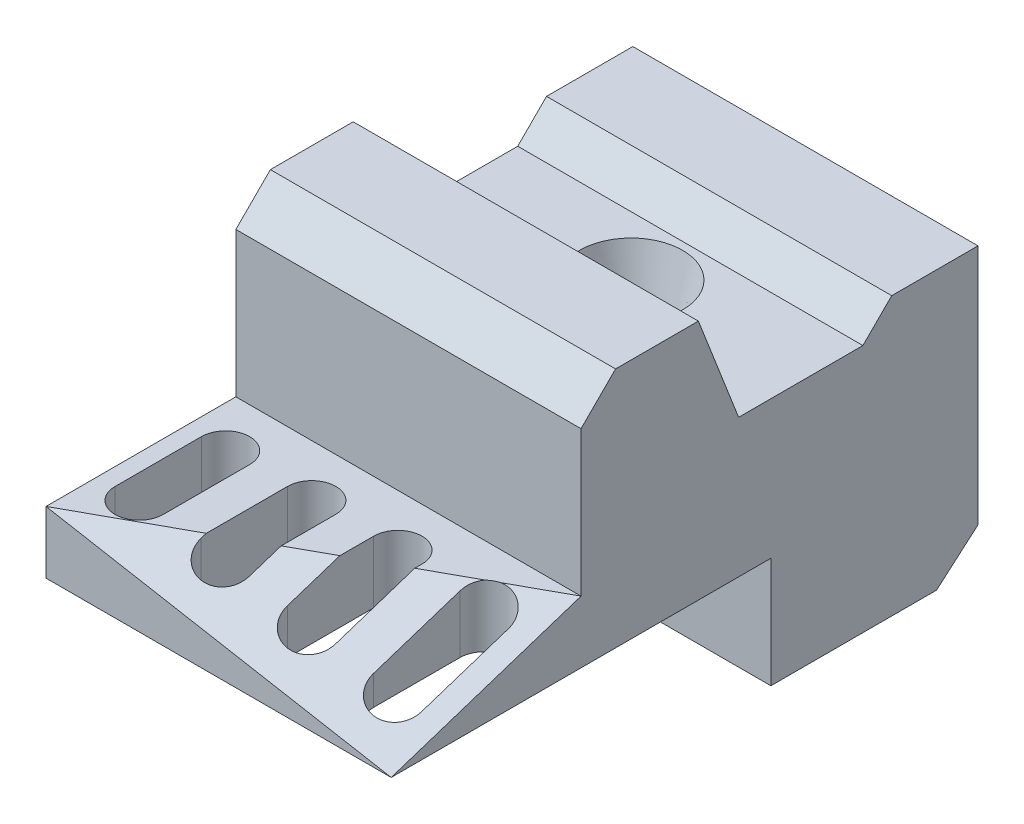
from build123d import *

# Parameters (mm, degrees)
RESSALTO_EXTRUS_O1_DEPTH = 100
CORTE_EXTRUS_O1_DEPTH    = 51.001510114
CORTE_EXTRUS_O4_DEPTH    = 87
CORTE_EXTRUS_O6_DEPTH    = 20
CORTE_EXTRUS_O8_REACH    = 104
ESBO_O10_R               = 9
ESBO_O12_R               = 14.94
CORTE_EXTRUS_O10_DEPTH   = 24.04
CORTE_EXTRUS_O10_TAPER   = 12.85


with BuildPart() as part:
    # Esboço3 → Ressalto-extrusão1 (new body)
    with BuildSketch(Plane(origin=(0, 0, 0), x_dir=(0, 0, -1), z_dir=(1, 0, 0))):
        Polygon((0, 0), (0, -70), (-12, -80.38), (-60, -80.38), (-60, -48.378489886), (-170, -48.378489886), (-170, -30.378489886), (-115, -30.378489886), (-115, 11.621510114), (-105.001510114, 21.62), (-81.001510114, 21.62), (-69.343860018, -8.343860018), (-33.343860018, -8.343860018), (-25, 0), align=None)
    extrude(amount=RESSALTO_EXTRUS_O1_DEPTH)

    # Esboço5 → Corte-extrusão1 (cut, through all)
    with BuildSketch(Plane(origin=(0, -30.378489886, 0), x_dir=(1, 0, 0), z_dir=(0, 1, 0))):
        with BuildLine():
            Line((5, -155.02), (5, -129.98))
            ThreePointArc((5, -129.98), (12, -122.98), (19, -129.98))
            Line((19, -129.98), (19, -155.02))
            ThreePointArc((19, -155.02), (12, -162.02), (5, -155.02))
        make_face()
        with BuildLine():
            Line((29.96, -155.02), (29.96, -129.98))
            ThreePointArc((29.96, -129.98), (36.96, -122.98), (43.96, -129.98))
            Line((43.96, -129.98), (43.96, -155.02))
            ThreePointArc((43.96, -155.02), (36.96, -162.02), (29.96, -155.02))
        make_face()
        with BuildLine():
            Line((54.92, -155.02), (54.92, -129.98))
            ThreePointArc((54.92, -129.98), (61.92, -122.98), (68.92, -129.98))
            Line((68.92, -129.98), (68.92, -155.02))
            ThreePointArc((68.92, -155.02), (61.92, -162.02), (54.92, -155.02))
        make_face()
        with BuildLine():
            Line((79.88, -155.02), (79.88, -129.98))
            ThreePointArc((79.88, -129.98), (86.88, -122.98), (93.88, -129.98))
            Line((93.88, -129.98), (93.88, -155.02))
            ThreePointArc((93.88, -155.02), (86.88, -162.02), (79.88, -155.02))
        make_face()
    extrude(amount=-CORTE_EXTRUS_O1_DEPTH, mode=Mode.SUBTRACT)

    # Esboço6 → Corte-extrusão4 (cut)
    with BuildSketch(Plane(origin=(3.989809214, 22.165606742, 7.25419857), x_dir=(0.985680811, -0.160257749, -0.052447991), z_dir=(0.168621878, 0.936788213, 0.306585233))):
        Polygon((-4.047769995, -171.016408889), (97.404950637, -176.615111976), (97.404950637, -118.744566791), align=None)
    extrude(amount=CORTE_EXTRUS_O4_DEPTH, mode=Mode.SUBTRACT)

    # Esboço9 → Corte-extrusão6 (cut)
    with BuildSketch(Plane.ZY):
        Polygon((105, 11.62), (87.841109365, 11.62), (76.183459269, -18.343860018), (29.781857804, -18.343860018), (21.437997786, -10), (10, -10), (10, -65.427954016), (15.724908652, -70.38), (50, -70.38), (50, -38.378489886), (105, -38.378489886), align=None)
    extrude(amount=-CORTE_EXTRUS_O6_DEPTH, mode=Mode.SUBTRACT)

    # Esboço10 → Corte-extrusão8 (cut, up to next)
    with BuildSketch(Plane.XZ.offset(80.38), mode=Mode.PRIVATE) as corte_extrus_o8_sk1:
        with Locations((50, 50.5)):
            Circle(ESBO_O10_R)
    corte_extrus_o8_tool1 = extrude(corte_extrus_o8_sk1.sketch, amount=-CORTE_EXTRUS_O8_REACH, mode=Mode.PRIVATE) & part.part
    add(corte_extrus_o8_tool1.solids().sort_by_distance((50, -80.38, 50.5))[0], mode=Mode.SUBTRACT)

    # Esboço12 → Corte-extrusão10 (cut)
    with BuildSketch(Plane(origin=(0, -8.343860018, 0), x_dir=(1, 0, 0), z_dir=(0, 1, 0))):
        with Locations((50, -50.5)):
            Circle(ESBO_O12_R)
    extrude(amount=-CORTE_EXTRUS_O10_DEPTH, taper=CORTE_EXTRUS_O10_TAPER, mode=Mode.SUBTRACT)


solid = part.part
